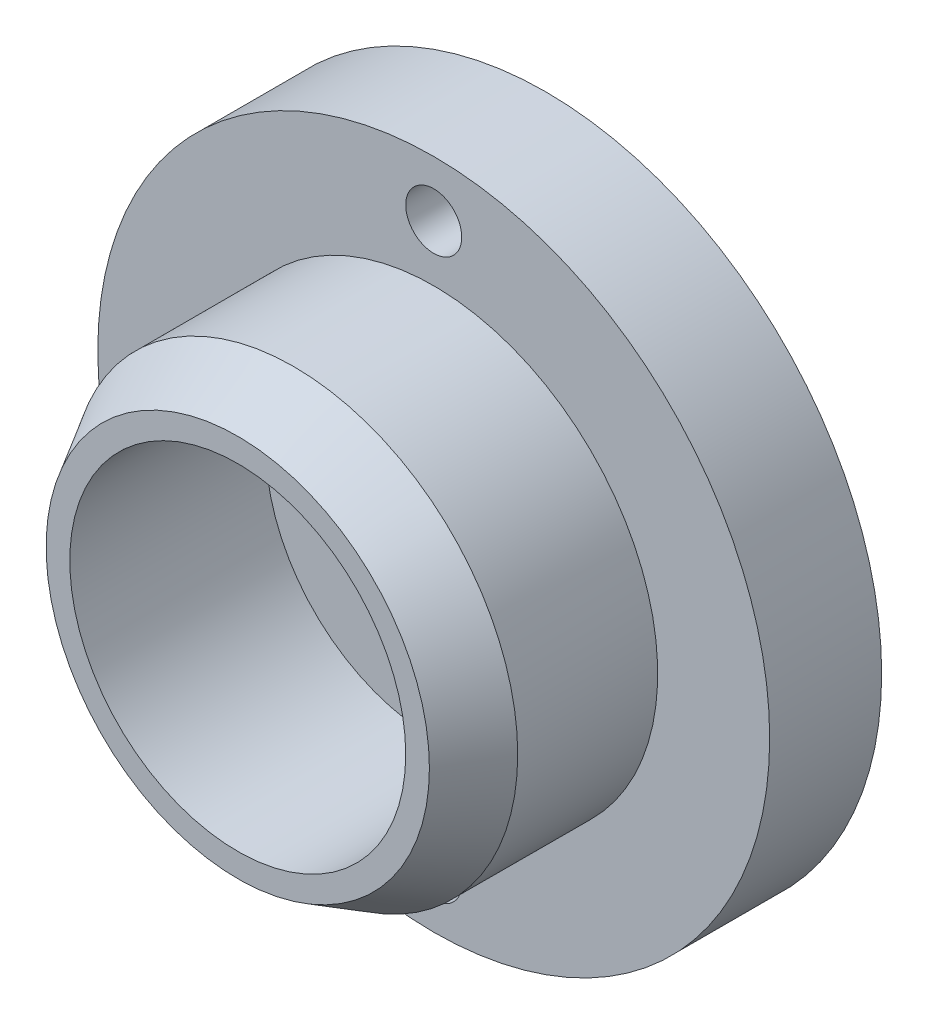
from build123d import *

# Parameters (mm, degrees)
SKETCH1_R           = 4
SKETCH1_R_2         = 3
BOSS_EXTRUDE1_DEPTH = 3.5
CHAMFER1_SIZE       = 1
CHAMFER1_SIZE2      = 0.577350269
SKETCH2_R           = 6
BOSS_EXTRUDE2_DEPTH = 2
SKETCH3_R           = 0.5
CUT_EXTRUDE1_DEPTH  = 2


with BuildPart() as part:
    # Sketch1 → Boss-Extrude1 (new body)
    with BuildSketch(Plane.XY):
        Circle(SKETCH1_R)
        Circle(SKETCH1_R_2, mode=Mode.SUBTRACT)
    extrude(amount=BOSS_EXTRUDE1_DEPTH)

    # Chamfer1
    chamfer1_edges = [part.edges().sort_by_distance(p)[0] for p in [
        (-4, 0, 3.5),
    ]]
    chamfer1_side = [part.faces().sort_by_distance(p)[0] for p in [
        (-4, 0, 1.75),
    ]]
    chamfer(chamfer1_edges, length=CHAMFER1_SIZE, length2=CHAMFER1_SIZE2, reference=chamfer1_side[0])

    # Sketch2 → Boss-Extrude2 (add)
    with BuildSketch(Plane(origin=(0, 0, 0), x_dir=(-1, 0, 0), z_dir=(0, 0, -1))):
        Circle(SKETCH2_R)
    extrude(amount=BOSS_EXTRUDE2_DEPTH)

    # Sketch3 → Cut-Extrude1 (cut)
    with BuildSketch(Plane.XY):
        with Locations((0, 5)):
            Circle(SKETCH3_R)
        with Locations((0, -5)):
            Circle(SKETCH3_R)
    extrude(amount=-CUT_EXTRUDE1_DEPTH, mode=Mode.SUBTRACT)


solid = part.part
